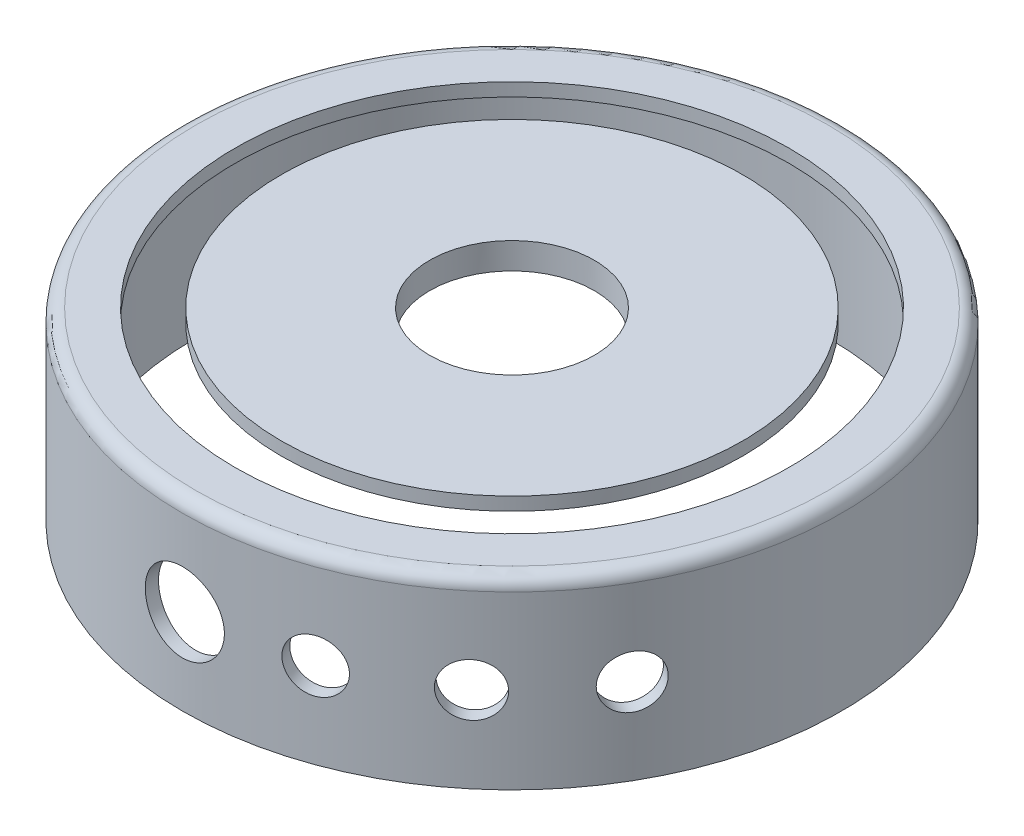
from build123d import *

# Parameters (mm, degrees)
SKETCH1_R           = 50
BOSS_EXTRUDE1_DEPTH = 28
SKETCH3_R           = 48
CUT_EXTRUDE1_DEPTH  = 26
SKETCH4_R           = 42
SKETCH4_R_2         = 35
CUT_EXTRUDE2_DEPTH  = 10
SKETCH5_R           = 12.5
CUT_EXTRUDE3_DEPTH  = 10
FILLET1_R           = 2
SKETCH6_R           = 4
CUT_EXTRUDE4_DEPTH  = 51
CIRPATTERN1_COUNT   = 4
CIRPATTERN1_ANGLE   = 60
SKETCH7_R           = 6
CUT_EXTRUDE5_DEPTH  = 51.000000101
SKETCH8_R           = 13.5
BOSS_EXTRUDE2_DEPTH = 2
SKETCH9_R           = 12.5
CUT_EXTRUDE6_DEPTH  = 5


with BuildPart() as part:
    # Sketch1 → Boss-Extrude1 (new body)
    with BuildSketch(Plane(origin=(0, 0, 0), x_dir=(1, 0, 0), z_dir=(0, 1, 0))):
        Circle(SKETCH1_R)
    extrude(amount=BOSS_EXTRUDE1_DEPTH)

    # Sketch3 → Cut-Extrude1 (cut)
    with BuildSketch(Plane.XZ):
        Circle(SKETCH3_R)
    extrude(amount=-CUT_EXTRUDE1_DEPTH, mode=Mode.SUBTRACT)

    # Sketch4 → Cut-Extrude2 (cut)
    with BuildSketch(Plane(origin=(0, 28, 0), x_dir=(1, 0, 0), z_dir=(0, 1, 0))):
        Circle(SKETCH4_R)
        Circle(SKETCH4_R_2, mode=Mode.SUBTRACT)
    extrude(amount=-CUT_EXTRUDE2_DEPTH, mode=Mode.SUBTRACT)

    # Sketch5 → Cut-Extrude3 (cut)
    with BuildSketch(Plane(origin=(0, 28, 0), x_dir=(1, 0, 0), z_dir=(0, 1, 0))):
        Circle(SKETCH5_R)
    extrude(amount=-CUT_EXTRUDE3_DEPTH, mode=Mode.SUBTRACT)

    # Fillet1
    fillet1_edges = [part.edges().sort_by_distance(p)[0] for p in [
        (-50, 28, 0),
    ]]
    fillet(fillet1_edges, radius=FILLET1_R)

    # Sketch6 → Cut-Extrude4 (cut, through all)
    with BuildSketch(Plane.XY):
        with Locations((0, 13)):
            Circle(SKETCH6_R)
    cut_extrude4 = extrude(amount=CUT_EXTRUDE4_DEPTH, mode=Mode.SUBTRACT)

    # CirPattern1: Cut-Extrude4 ×4 about axis
    cirpattern1_axis = Axis((0, 26, 0), (0, 1, 0))
    for i in range(1, CIRPATTERN1_COUNT):
        add(cut_extrude4.rotate(cirpattern1_axis, i * CIRPATTERN1_ANGLE / (CIRPATTERN1_COUNT - 1)), mode=Mode.SUBTRACT)

    # Sketch7 → Cut-Extrude5 (cut, through all)
    with BuildSketch(Plane.XY):
        with Locations((0, 13)):
            Circle(SKETCH7_R)
    extrude(amount=CUT_EXTRUDE5_DEPTH, mode=Mode.SUBTRACT)

    # Sketch8 → Boss-Extrude2 (add)
    with BuildSketch(Plane.XZ.offset(-26)):
        Circle(SKETCH8_R)
    extrude(amount=BOSS_EXTRUDE2_DEPTH)

    # Sketch9 → Cut-Extrude6 (cut, through all)
    with BuildSketch(Plane.XZ.offset(-24)):
        Circle(SKETCH9_R)
    extrude(amount=-CUT_EXTRUDE6_DEPTH, mode=Mode.SUBTRACT)


solid = part.part
